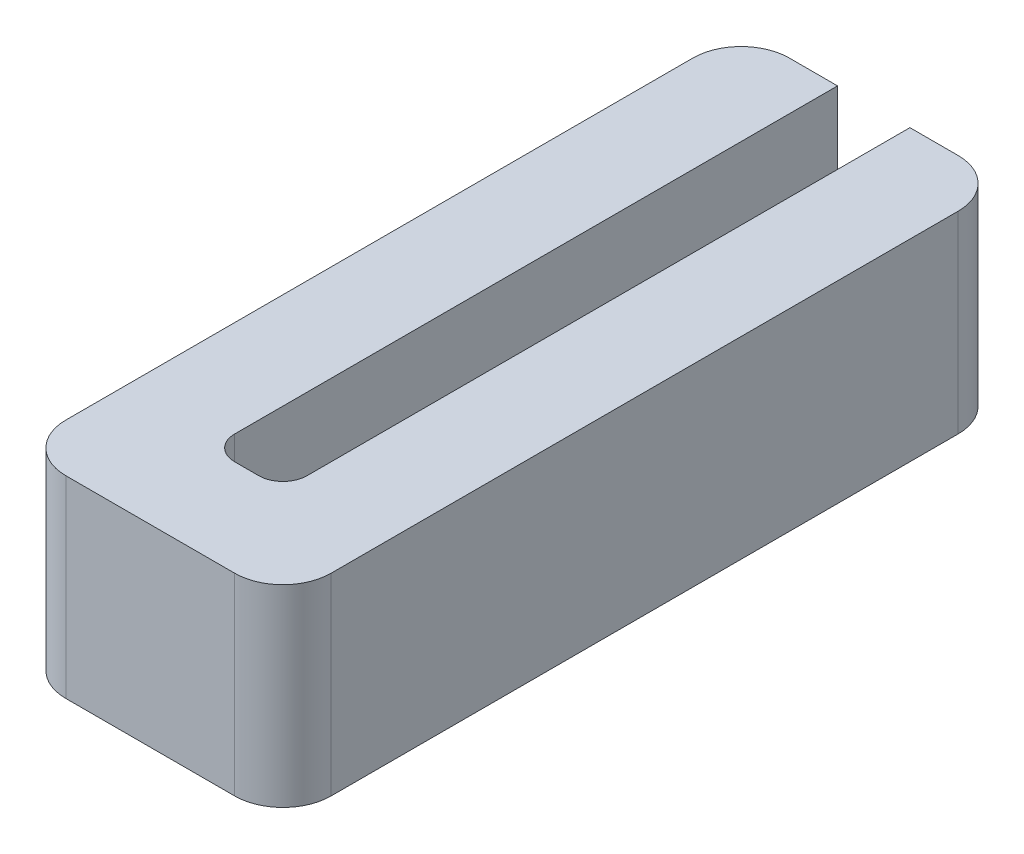
from build123d import *

# Parameters (mm, degrees)
SALIENTE_EXTRUIR1_DEPTH = 4
REDONDEO1_R             = 1
REDONDEO2_R             = 0.5


with BuildPart() as part:
    # Croquis1 → Saliente-Extruir1 (new body)
    with BuildSketch(Plane(origin=(0, 0, 0), x_dir=(1, 0, 0), z_dir=(0, 1, 0))):
        Polygon((3.5, 0), (5.5, 0), (5.5, -15), (0, -15), (0, 0), (2, 0), (2, -13), (3.5, -13), align=None)
    extrude(amount=SALIENTE_EXTRUIR1_DEPTH)

    # Redondeo1
    redondeo1_edges = [part.edges().sort_by_distance(p)[0] for p in [
        (0, 2, 0),
        (5.5, 2, 0),
        (5.5, 2, 15),
        (0, 2, 15),
    ]]
    fillet(redondeo1_edges, radius=REDONDEO1_R)

    # Redondeo2
    redondeo2_edges = [part.edges().sort_by_distance(p)[0] for p in [
        (2, 2, 13),
        (3.5, 2, 13),
    ]]
    fillet(redondeo2_edges, radius=REDONDEO2_R)


solid = part.part
